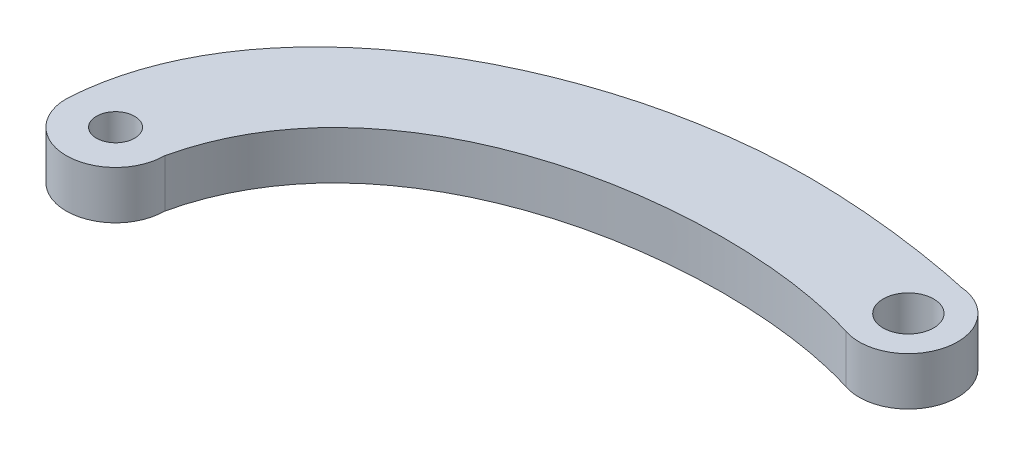
from build123d import *

# Parameters (mm, degrees)
SKETCH1_R           = 1.55
SKETCH1_R_2         = 2.05
BOSS_EXTRUDE1_DEPTH = 3.9


with BuildPart() as part:
    # Sketch1 → Boss-Extrude1 (new body)
    with BuildSketch(Plane(origin=(0, 0, 0), x_dir=(1, 0, 0), z_dir=(0, 1, 0))):
        with BuildLine():
            ThreePointArc((-14.820025451, -5.215177733), (-10.820025451, -9.215177733), (-6.820025451, -5.215177733))
            add(Edge.make_bspline(
                [(-6.820025451, -5.215177733), (-3.10433649, 11.226211993), (20.304386061, 14.090059899), (33.181268574, 10.099401317)],
                knots=[0, 0, 0, 0, 1, 1, 1, 1], degree=3))
            ThreePointArc((33.181268574, 10.099401317), (38.392505906, 13.07023944), (34.796153323, 17.871189532))
            add(Edge.make_bspline(
                [(-14.820025451, -5.215177733), (-14.024891934, 9.668323316), (10.780534752, 22.947844535), (33.5182405, 18.169051386), (34.796153323, 17.871189532)],
                knots=[0, 0, 0, 0, 0.692921381, 1, 1, 1, 1], degree=3))
        make_face()
        with Locations((-10.820025451, -5.215177733)):
            Circle(SKETCH1_R, mode=Mode.SUBTRACT)
        with Locations((34.476158372, 13.884009673)):
            Circle(SKETCH1_R_2, mode=Mode.SUBTRACT)
    extrude(amount=BOSS_EXTRUDE1_DEPTH)


solid = part.part
